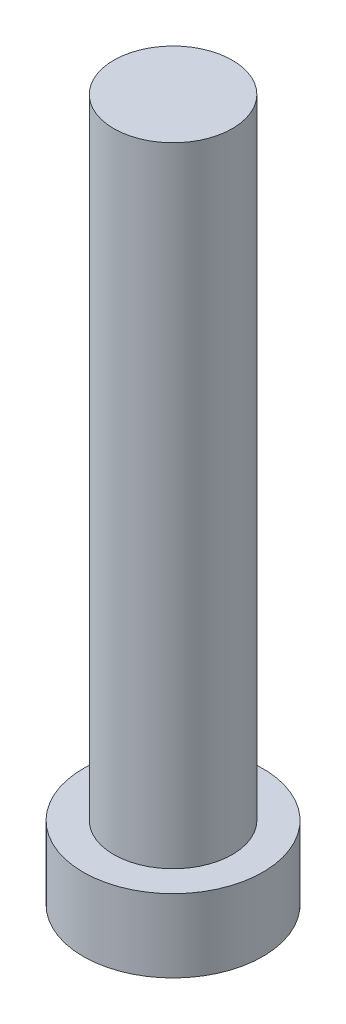
from build123d import *

# Parameters (mm, degrees)
SKETCH1_R           = 5
BOSS_EXTRUDE1_DEPTH = 4.064
BOSS_EXTRUDE2_START = -4.064
SKETCH2_R           = 3.3
BOSS_EXTRUDE2_DEPTH = 39.0652


with BuildPart() as part:
    # Sketch1 → Boss-Extrude1 (new body)
    with BuildSketch(Plane(origin=(0, 0, 0), x_dir=(1, 0, 0), z_dir=(0, 1, 0))):
        Circle(SKETCH1_R)
    extrude(amount=BOSS_EXTRUDE1_DEPTH)

    # Sketch2 → Boss-Extrude2 (add)
    with BuildSketch(Plane(origin=(0, 4.064, 0), x_dir=(1, 0, 0), z_dir=(0, 1, 0)).offset(BOSS_EXTRUDE2_START)):
        Circle(SKETCH2_R)
    extrude(amount=BOSS_EXTRUDE2_DEPTH)


solid = part.part
